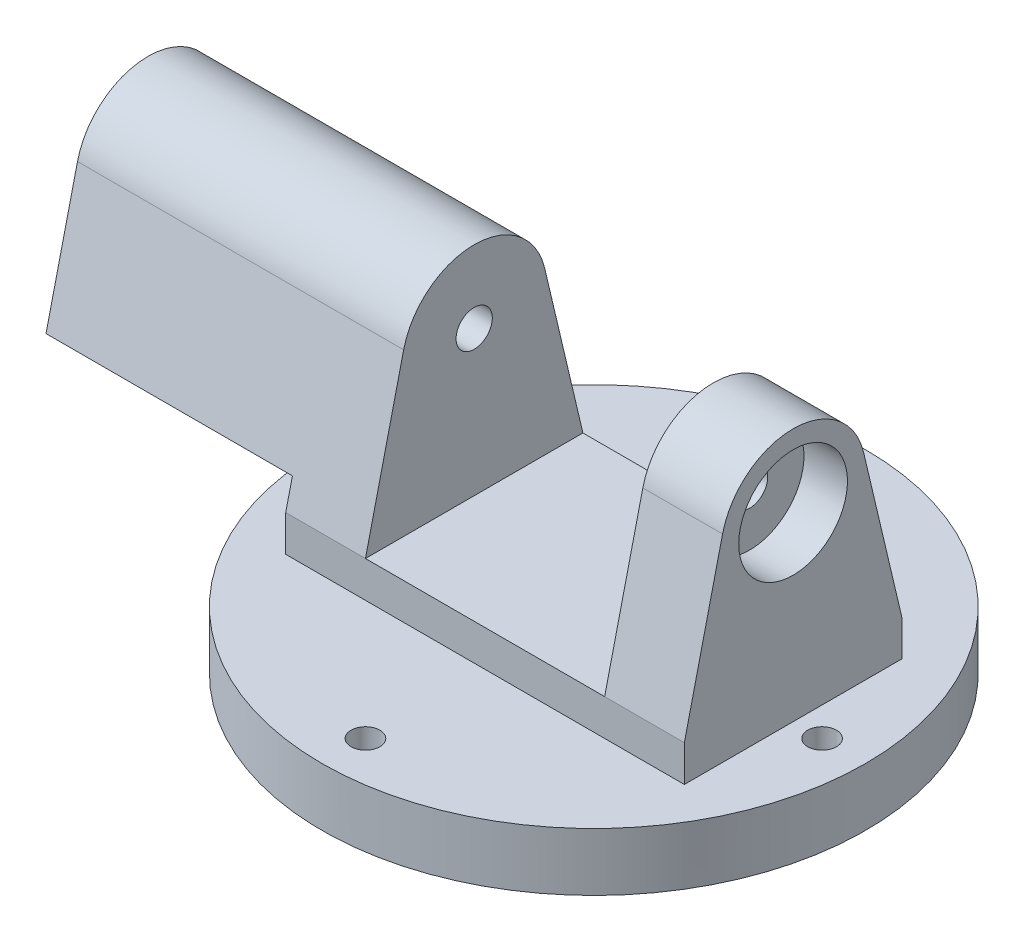
from build123d import *

# Parameters (mm, degrees)
CROQUIS1_R              = 75
SALIENTE_EXTRUIR1_DEPTH = 8
CROQUIS2_R              = 3.97
CORTAR_EXTRUIR1_DEPTH   = 20
SALIENTE_EXTRUIR2_DEPTH = 10
SALIENTE_EXTRUIR3_DEPTH = 22
CROQUIS5_R              = 15
CORTAR_EXTRUIR2_DEPTH   = 12
CROQUIS6_R              = 5
CORTAR_EXTRUIR3_DEPTH   = 126
CROQUIS7_R              = 15
SALIENTE_EXTRUIR4_DEPTH = 68
CROQUIS8_R              = 75
SALIENTE_EXTRUIR5_DEPTH = 8
CROQUIS9_R              = 15
CROQUIS9_R_2            = 13
SALIENTE_EXTRUIR6_DEPTH = 18


with BuildPart() as part:
    # Croquis1 → Saliente-Extruir1 (new body)
    with BuildSketch(Plane(origin=(0, 0, 0), x_dir=(1, 0, 0), z_dir=(0, 1, 0))):
        Circle(CROQUIS1_R)
    extrude(amount=SALIENTE_EXTRUIR1_DEPTH)

    # Croquis2 → Cortar-Extruir1 (cut)
    with BuildSketch(Plane(origin=(0, 8, 0), x_dir=(1, 0, 0), z_dir=(0, 1, 0))):
        with Locations((0, 63)):
            Circle(CROQUIS2_R)
        with Locations((63, 0)):
            Circle(CROQUIS2_R)
        with Locations((0, -63)):
            Circle(CROQUIS2_R)
        with Locations((-63, 0)):
            Circle(CROQUIS2_R)
    extrude(amount=-CORTAR_EXTRUIR1_DEPTH, mode=Mode.SUBTRACT)

    # Croquis3 → Saliente-Extruir2 (add)
    with BuildSketch(Plane(origin=(0, 8, 0), x_dir=(1, 0, 0), z_dir=(0, 1, 0))):
        Polygon((-55, 0), (-55, 30), (55, 30), (55, 0), (55, -30), (-55, -30), align=None)
    extrude(amount=SALIENTE_EXTRUIR2_DEPTH)

    # Croquis4 → Saliente-Extruir3 (add)
    with BuildSketch(Plane(origin=(55, 0, 0), x_dir=(0, 0, -1), z_dir=(1, 0, 0))):
        with BuildLine():
            Line((-30, 18), (30, 18))
            Line((30, 18), (19.464281728, 62.598174498))
            ThreePointArc((19.464281728, 62.598174498), (0, 78.000036798), (-19.464281728, 62.598174498))
            Line((-19.464281728, 62.598174498), (-30, 18))
        make_face()
    saliente_extruir3 = extrude(amount=-SALIENTE_EXTRUIR3_DEPTH)

    # Simetría1: Saliente-Extruir3 across plane
    add(saliente_extruir3.mirror(Plane(origin=(0, 0, 0), x_dir=(0, 0, 1), z_dir=(1, 0, 0))))

    # Croquis5 → Cortar-Extruir2 (cut)
    with BuildSketch(Plane.ZY.offset(55)):
        with Locations((0, 58)):
            Circle(CROQUIS5_R)
    cortar_extruir2 = extrude(amount=-CORTAR_EXTRUIR2_DEPTH, mode=Mode.SUBTRACT)

    # Simetría2: Cortar-Extruir2 across plane
    add(cortar_extruir2.mirror(Plane(origin=(0, 0, 0), x_dir=(0, 0, 1), z_dir=(1, 0, 0))), mode=Mode.SUBTRACT)

    # Croquis6 → Cortar-Extruir3 (cut)
    with BuildSketch(Plane.ZY.offset(43)):
        with Locations((0, 58)):
            Circle(CROQUIS6_R)
    extrude(amount=-CORTAR_EXTRUIR3_DEPTH, mode=Mode.SUBTRACT)

    # Croquis7 → Saliente-Extruir4 (add)
    with BuildSketch(Plane.ZY.offset(55)):
        with BuildLine():
            Line((-19.464281728, 62.598174498), (-28.151527476, 25.824668242))
            Line((-28.151527476, 25.824668242), (28.151527476, 25.824668242))
            Line((28.151527476, 25.824668242), (19.464281728, 62.598174498))
            ThreePointArc((19.464281728, 62.598174498), (0, 78.000036798), (-19.464281728, 62.598174498))
        make_face()
        with Locations((0, 58)):
            Circle(CROQUIS7_R, mode=Mode.SUBTRACT)
    extrude(amount=SALIENTE_EXTRUIR4_DEPTH)

    # Croquis8 → Saliente-Extruir5 (add)
    with BuildSketch(Plane.XZ):
        Circle(CROQUIS8_R)
    extrude(amount=SALIENTE_EXTRUIR5_DEPTH)

    # Croquis9 → Saliente-Extruir6 (add)
    with BuildSketch(Plane.XZ.offset(8)):
        Circle(CROQUIS9_R)
        Circle(CROQUIS9_R_2, mode=Mode.SUBTRACT)
    extrude(amount=SALIENTE_EXTRUIR6_DEPTH)


solid = part.part
